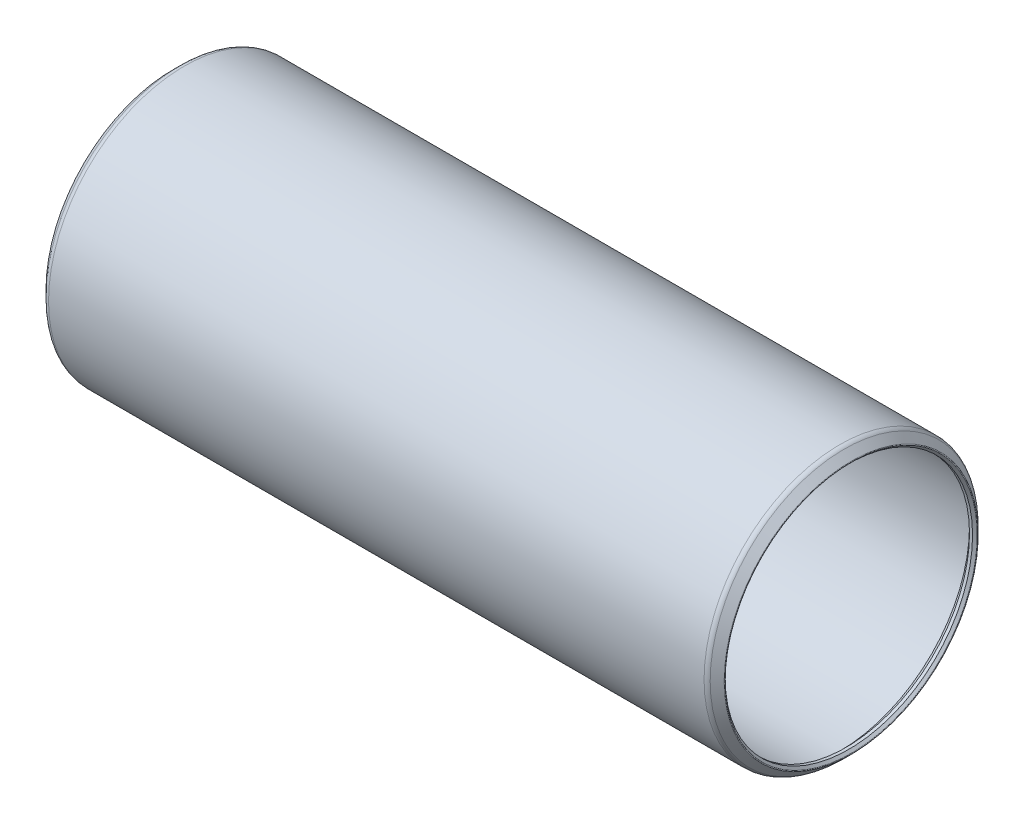
from build123d import *


with BuildPart() as part:
    # Sketch1 → Revolve1 (revolve)
    with BuildSketch(Plane.XY):
        with BuildLine():
            Line((-0.919083697, 21.734383697), (-0.52705, 21.34235))
            Line((-0.52705, 21.34235), (0, 21.34235))
            Line((0, 21.34235), (1.0541, 22.39645))
            Line((1.0541, 22.39645), (114.0968, 22.39645))
            Line((114.0968, 22.39645), (115.1509, 21.34235))
            Line((115.1509, 21.34235), (115.67795, 21.34235))
            Line((115.67795, 21.34235), (116.069983697, 21.734383697))
            ThreePointArc((116.069983697, 21.734383697), (116.107181136, 21.824186258), (116.069983697, 21.913988819))
            Line((116.069983697, 21.913988819), (114.867561258, 23.116411258))
            ThreePointArc((114.867561258, 23.116411258), (114.525586606, 23.344911415), (114.1222, 23.42515))
            Line((114.1222, 23.42515), (1.0287, 23.42515))
            ThreePointArc((1.0287, 23.42515), (0.625313394, 23.344911415), (0.283338742, 23.116411258))
            Line((0.283338742, 23.116411258), (-0.919083697, 21.913988819))
            ThreePointArc((-0.919083697, 21.913988819), (-0.956281136, 21.824186258), (-0.919083697, 21.734383697))
        make_face()
    revolve(axis=Axis((115.1509, 0, 0), (-1, 0, 0)))


solid = part.part
